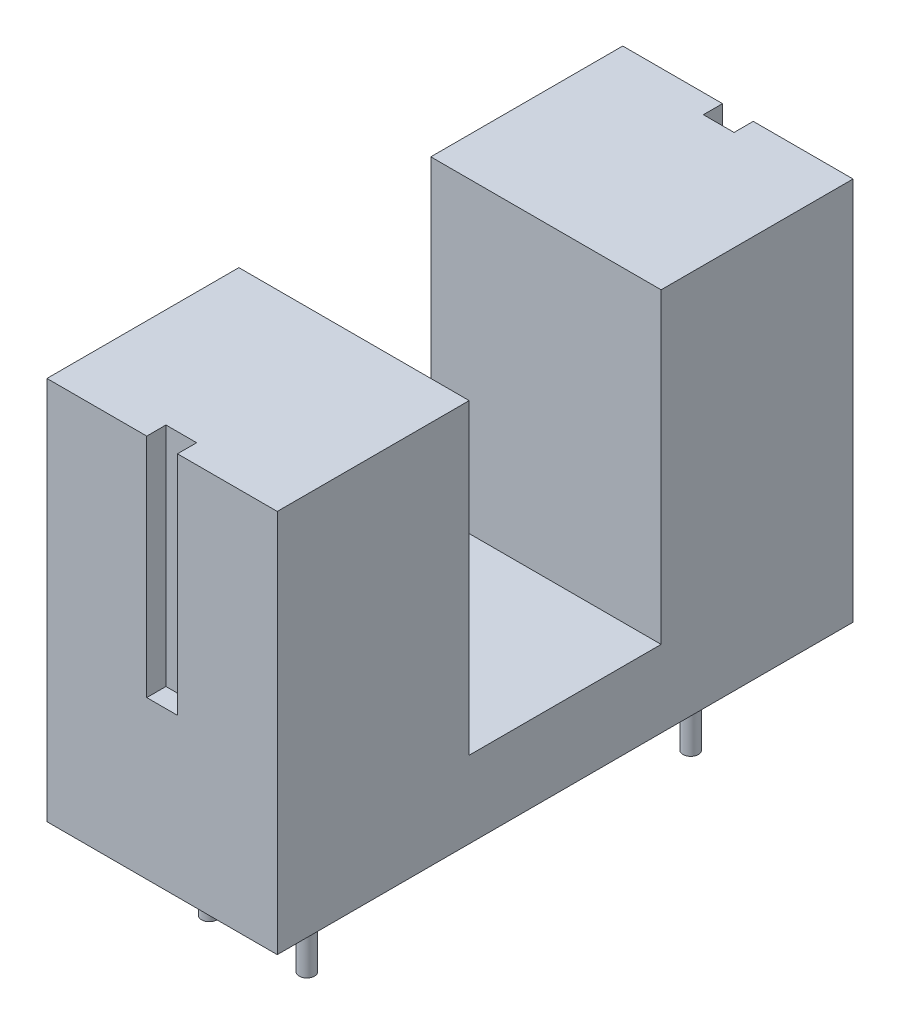
from build123d import *

# Parameters (mm, degrees)
BOSS_EXTRUDE1_DEPTH = 6
SKETCH2_W           = 0.8
SKETCH2_H           = 5.9
CUT_EXTRUDE1_DEPTH  = 0.5
SKETCH3_R           = 0.2
BOSS_EXTRUDE2_DEPTH = 2.5


with BuildPart() as part:
    # Sketch1 → Boss-Extrude1 (new body)
    with BuildSketch(Plane(origin=(0, 0, 0), x_dir=(0, 0, -1), z_dir=(1, 0, 0))):
        Polygon((-7.5, -6.8), (-7.5, 3.2), (-2.5, 3.2), (-2.5, -4.8), (2.5, -4.8), (2.5, 3.2), (7.5, 3.2), (7.5, -6.8), align=None)
    extrude(amount=BOSS_EXTRUDE1_DEPTH)

    # Sketch2 → Cut-Extrude1 (cut)
    with BuildSketch(Plane(origin=(0, 0, -7.5), x_dir=(-1, 0, 0), z_dir=(0, 0, -1))):
        with Locations((-3, 0.25)):
            Rectangle(SKETCH2_W, SKETCH2_H)
    cut_extrude1 = extrude(amount=-CUT_EXTRUDE1_DEPTH, mode=Mode.SUBTRACT)

    # Mirror1: Cut-Extrude1 across plane
    add(cut_extrude1.mirror(Plane.XY), mode=Mode.SUBTRACT)

    # Sketch3 → Boss-Extrude2 (add)
    with BuildSketch(Plane.XZ.offset(6.8)):
        with Locations((1.73, -5)):
            Circle(SKETCH3_R)
        with Locations((4.27, -5)):
            Circle(SKETCH3_R)
        with Locations((4.27, 5)):
            Circle(SKETCH3_R)
        with Locations((1.73, 5)):
            Circle(SKETCH3_R)
    extrude(amount=BOSS_EXTRUDE2_DEPTH)


solid = part.part
